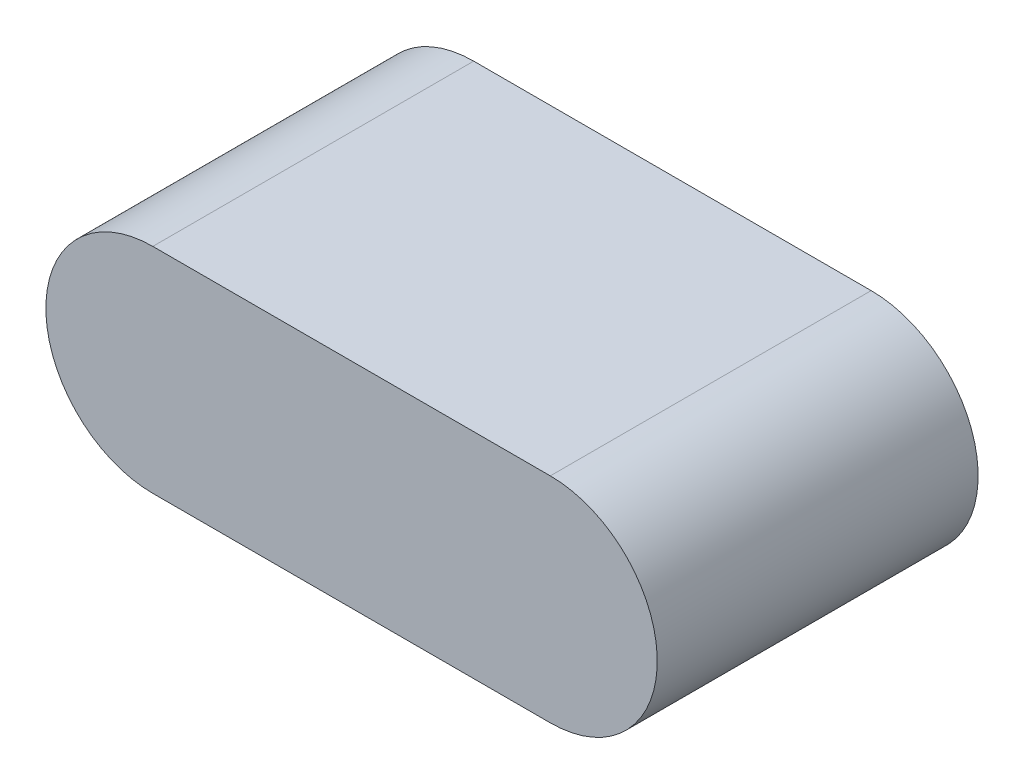
from build123d import *

# Parameters (mm, degrees)
BOSS_EXTRUDE1_DEPTH = 3


with BuildPart() as part:
    # Sketch1 → Boss-Extrude1 (new body)
    with BuildSketch(Plane.XY):
        with BuildLine():
            Line((-27.076358763, -13.519616816), (-23.360204913, -13.519616816))
            ThreePointArc((-23.360204913, -13.519616816), (-22.360204913, -14.519616816), (-23.360204913, -15.519616816))
            Line((-23.360204913, -15.519616816), (-27.076358763, -15.519616816))
            ThreePointArc((-27.076358763, -15.519616816), (-28.076358763, -14.519616816), (-27.076358763, -13.519616816))
        make_face()
    extrude(amount=BOSS_EXTRUDE1_DEPTH)


solid = part.part
